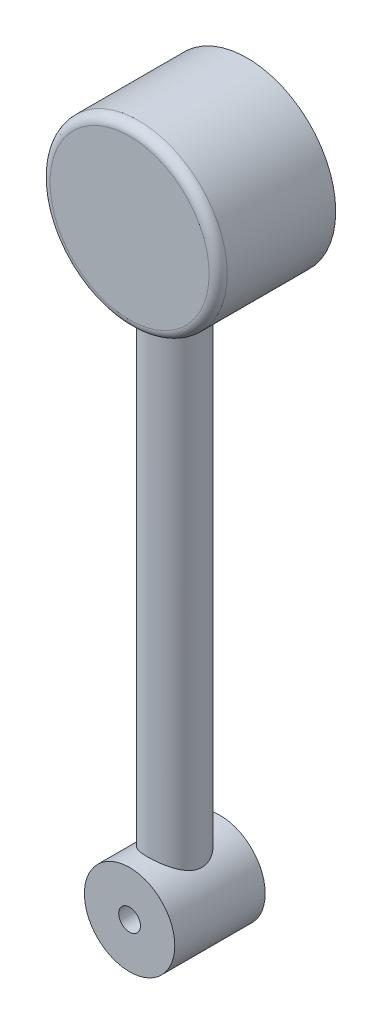
from build123d import *

# Parameters (mm, degrees)
SKETCH_1_R               = 4.9
EXTRUDE_1_DEPTH          = 6.5
SKETCH_7_R               = 3.4
CUT_EXTRUDE_1_DEPTH      = 5.5
SKETCH_8_R               = 1.5
CUT_EXTRUDE_6_DEPTH      = 5.9
FILLET_3_R               = 0.5
SKETCH_15_R              = 2.5
EXTRUDE_6_DEPTH          = 2.5
EXTRUDE_6_DEPTH_BACK     = 2.5
SKETCH_16_R              = 1.5
CUT_EXTRUDE_7_DEPTH      = 2.5
CUT_EXTRUDE_7_DEPTH_BACK = 2.5
SKETCH_17_R              = 0.6
CUT_EXTRUDE_8_DEPTH      = 7.5000001
SKETCH_18_R              = 1.5
EXTRUDE_7_DEPTH          = 29


with BuildPart() as part:
    # Sketch 1 → Extrude 1 (new body)
    with BuildSketch(Plane.XY):
        Circle(SKETCH_1_R)
    extrude(amount=-EXTRUDE_1_DEPTH)

    # Sketch 7 → Cut-Extrude 1 (cut)
    with BuildSketch(Plane(origin=(0, 0, -6.5), x_dir=(-1, 0, 0), z_dir=(0, 0, -1))):
        Circle(SKETCH_7_R)
    extrude(amount=-CUT_EXTRUDE_1_DEPTH, mode=Mode.SUBTRACT)

    # Sketch 8 → Cut-Extrude 6 (cut, through all)
    with BuildSketch(Plane(origin=(0, 0, 0), x_dir=(1, 0, 0), z_dir=(0, 1, 0))):
        with Locations(Location((0, 2.5, 0), (0, 0, 270))):  # turned: the seam where the file's is
            Circle(SKETCH_8_R)
    extrude(amount=-CUT_EXTRUDE_6_DEPTH, mode=Mode.SUBTRACT)

    # Fillet 3
    fillet_3_edges = [part.edges().sort_by_distance(p)[0] for p in [
        (-4.9, 0, 0),
    ]]
    fillet(fillet_3_edges, radius=FILLET_3_R)



with BuildPart() as body_2:
    # Sketch 15 → Extrude 6 (new body, two sides)
    with BuildSketch(Plane.XY.offset(-2.5)) as extrude_6_sk:
        with Locations((0, -33.125)):
            Circle(SKETCH_15_R)
    extrude(amount=EXTRUDE_6_DEPTH)
    extrude(extrude_6_sk.sketch, amount=-EXTRUDE_6_DEPTH_BACK)

    # Sketch 16 → Cut-Extrude 7 (cut, two sides)
    with BuildSketch(Plane(origin=(0, -33.125, 0), x_dir=(1, 0, 0), z_dir=(0, 1, 0))) as cut_extrude_7_sk:
        with Locations(Location((0, 2.5, 0), (0, 0, 270))):  # turned: the seam where the file's is
            Circle(SKETCH_16_R)
    extrude(amount=CUT_EXTRUDE_7_DEPTH, mode=Mode.SUBTRACT)
    extrude(cut_extrude_7_sk.sketch, amount=-CUT_EXTRUDE_7_DEPTH_BACK, mode=Mode.SUBTRACT)

    # Sketch 17 → Cut-Extrude 8 (cut, through all)
    with BuildSketch(Plane.XY):
        with Locations((0, -33.125)):
            Circle(SKETCH_17_R)
    extrude(amount=-CUT_EXTRUDE_8_DEPTH, mode=Mode.SUBTRACT)


with BuildPart() as part_1:
    add(part.part)

    add(body_2.part)  # Extrude 7 merges body 2
    # Sketch 18 → Extrude 7 (add)
    with BuildSketch(Plane(origin=(0, -33.125, 0), x_dir=(1, 0, 0), z_dir=(0, 1, 0))):
        with Locations(Location((0, 2.5, 0), (0, 0, 270))):  # turned: the seam where the file's is
            Circle(SKETCH_18_R)
    extrude(amount=EXTRUDE_7_DEPTH)


solid = part_1.part
